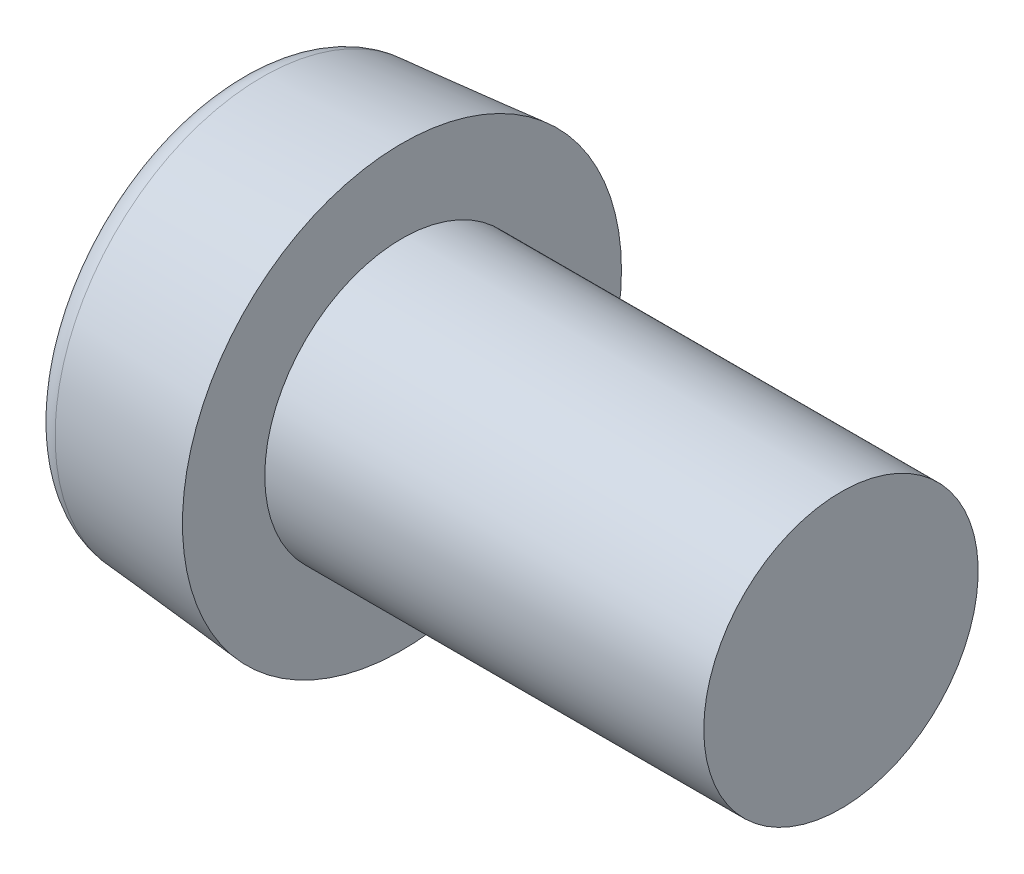
from build123d import *

# Parameters (mm, degrees)
SKETCH1_R      = 8
BASEHEAD_DEPTH = 6
BASEHEAD_DRAFT = -5
SKETCH8_W      = 16
SKETCH8_H      = 5
SOCKET_DEPTH   = 3
HEADFILLET2_R  = 1


with BuildPart() as part:
    # Sketch1 → BaseHead (with draft: the straight prism first)
    with BuildSketch(Plane(origin=(6, 0, 0), x_dir=(0, 0, -1), z_dir=(1, 0, 0))):
        Circle(SKETCH1_R)
    extrude(amount=-BASEHEAD_DEPTH)
    # BaseHead: the draft: its side faces are tilted about the plane it starts from
    basehead_sides = [part.faces().sort_by_distance(p)[0] for p in [
        (3, 0, 8),
    ]]
    draft(basehead_sides, Plane(origin=(6, 0, 0), x_dir=(0, 0, -1), z_dir=(1, 0, 0)), BASEHEAD_DRAFT)

    # Sketch8 → Revolve1 (revolve)
    with BuildSketch(Plane.XY, mode=Mode.PRIVATE) as revolve1_sk:
        with Locations((14, 2.5)):
            Rectangle(SKETCH8_W, SKETCH8_H)
    revolve(revolve1_sk.sketch.rotate(Axis((0, 0, 0), (1, 0, 0)), 90), axis=Axis((0, 0, 0), (1, 0, 0)))

    # Sketch4 → Socket (cut)
    with BuildSketch(Plane(origin=(0, 0, 0), x_dir=(0, 0, -1), z_dir=(1, 0, 0))):
        with BuildLine():
            add(Edge.make_bspline(
                [(1.655, 2.866544087), (2.291538462, 2.499038434), (3.819230769, 2.205033913), (3.055384615, 0), (3.819230769, -2.205033913), (1.527692308, -2.646040695), (0, -4.410067825), (-1.527692308, -2.646040695), (-3.819230769, -2.205033913), (-3.055384615, 0), (-3.819230769, 2.205033913), (-1.527692308, 2.646040695), (0, 4.410067825), (1.018461538, 3.234049739), (1.655, 2.866544087)],
                knots=[0, 0, 0, 0, 0.083333333, 0.166666667, 0.25, 0.333333333, 0.416666667, 0.5, 0.583333333, 0.666666667, 0.75, 0.833333333, 0.916666667, 1, 1, 1, 1], degree=3))
        make_face()
    extrude(amount=SOCKET_DEPTH, mode=Mode.SUBTRACT)

    # Sketch5 → Cut-Loft1 section 0
    with BuildSketch(Plane.ZY.offset(-3), mode=Mode.PRIVATE) as cut_loft1_s0:
        with BuildLine():
            add(Edge.make_bspline(
                [(-1.655, 2.866544087), (-2.291538462, 2.499038434), (-3.819230769, 2.205033913), (-3.055384615, 0), (-3.819230769, -2.205033913), (-1.527692308, -2.646040695), (0, -4.410067825), (1.527692308, -2.646040695), (3.819230769, -2.205033913), (3.055384615, 0), (3.819230769, 2.205033913), (1.527692308, 2.646040695), (0, 4.410067825), (-1.018461538, 3.234049739), (-1.655, 2.866544087)],
                knots=[0, 0, 0, 0, 0.083333333, 0.166666667, 0.25, 0.333333333, 0.416666667, 0.5, 0.583333333, 0.666666667, 0.75, 0.833333333, 0.916666667, 1, 1, 1, 1], degree=3))
        make_face()
    loft([Vertex(4, 0, 0), cut_loft1_s0.sketch], mode=Mode.SUBTRACT)

    # HeadFillet2
    headfillet2_edges = [part.edges().sort_by_distance(p)[0] for p in [
        (0, 0, 7.475068019),
    ]]
    fillet(headfillet2_edges, radius=HEADFILLET2_R)


solid = part.part
